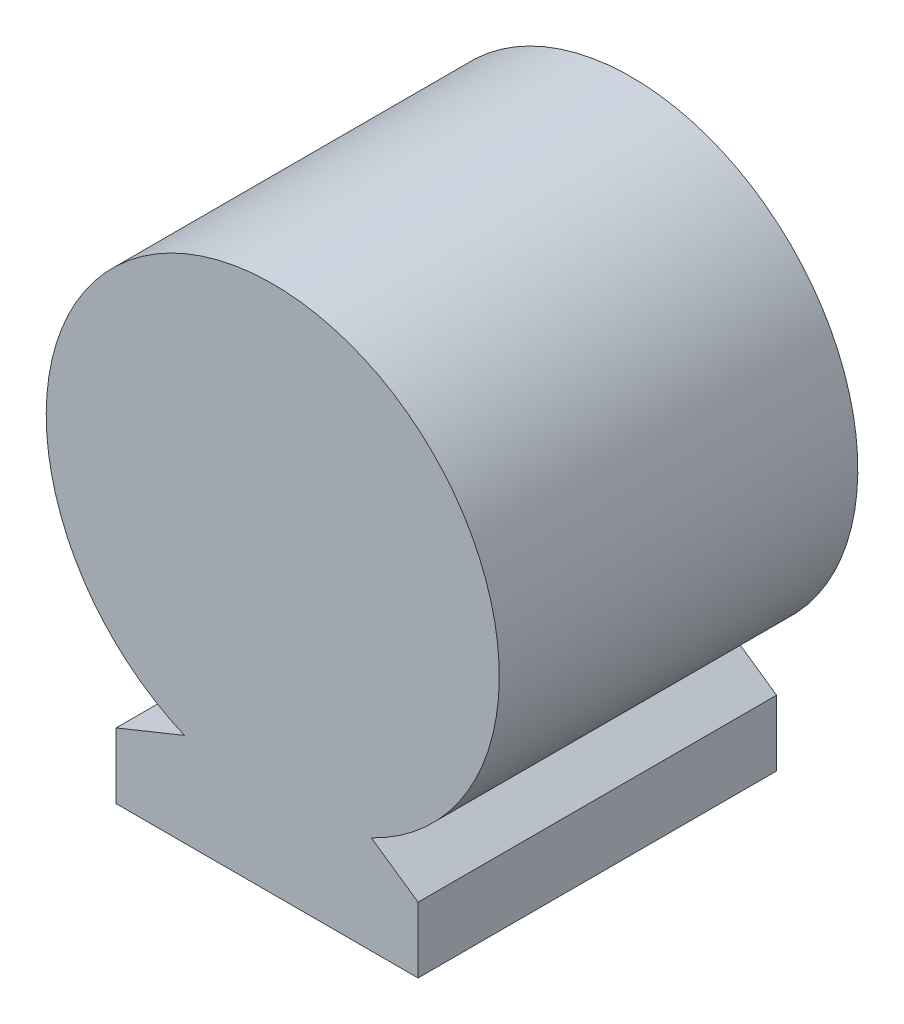
from build123d import *

# Parameters (mm, degrees)
DODANIE_WYCI_GNI_CIE1_DEPTH = 95


with BuildPart() as part:
    # Szkic1 → Dodanie-wyciągnięcie1 (new body)
    with BuildSketch(Plane.XY):
        with BuildLine():
            Line((-41.5, -80), (38.5, -80))
            Line((38.5, -80), (38.5, -62.609546875))
            Line((38.5, -62.609546875), (26.120922852, -54.03653754))
            ThreePointArc((26.120922852, -54.03653754), (-1.5, 60), (-23.388152803, -55.274264432))
            Line((-23.388152803, -55.274264432), (-41.5, -62.609546875))
            Line((-41.5, -62.609546875), (-41.5, -80))
        make_face()
    extrude(amount=DODANIE_WYCI_GNI_CIE1_DEPTH)


solid = part.part
